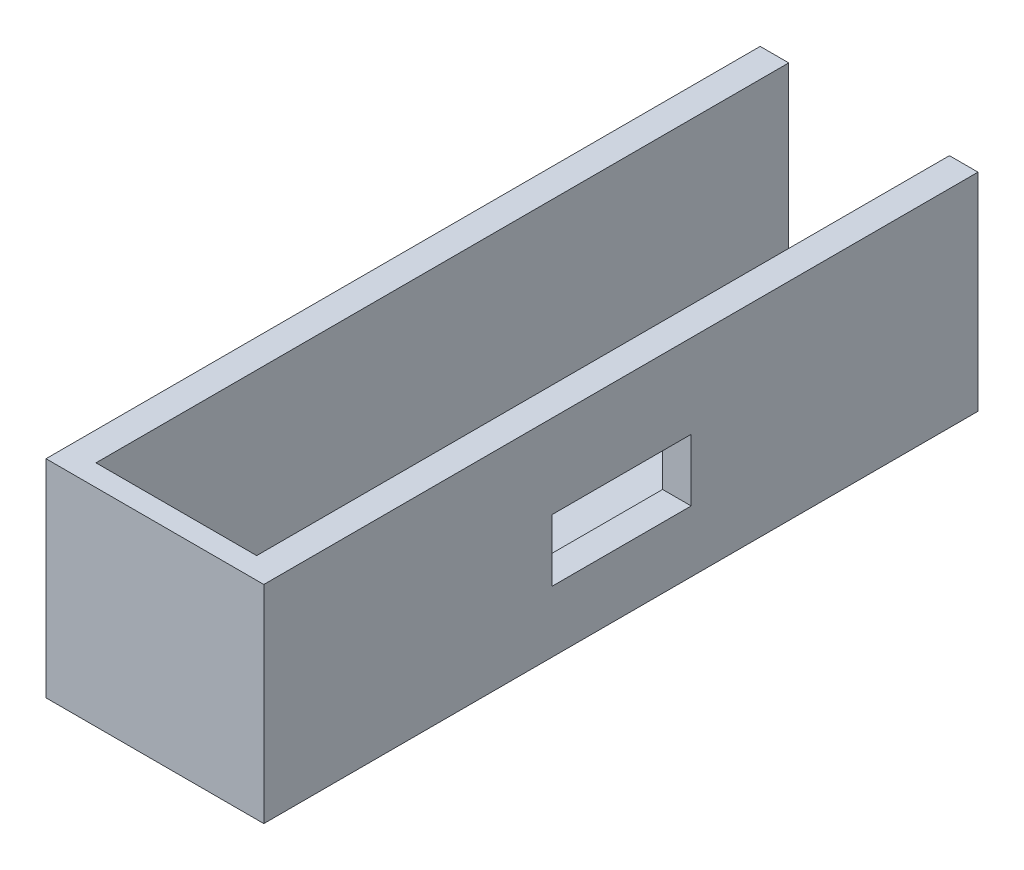
from build123d import *

# Parameters (mm, degrees)
BOSS_EXTRUDE1_DEPTH = 50
SKETCH2_W           = 30.5
SKETCH2_H           = 29
BOSS_EXTRUDE2_DEPTH = 3
SKETCH3_W           = 19.5
SKETCH3_H           = 8.69
CUT_EXTRUDE1_DEPTH  = 30


with BuildPart() as part:
    # Sketch1 → Boss-Extrude1 (new body, symmetric)
    with BuildSketch(Plane.XY):
        Polygon((-9.848648649, 0), (-9.848648649, -25), (12.651351351, -25), (12.651351351, 0), (16.651351351, 0), (16.651351351, -29), (-13.848648649, -29), (-13.848648649, 0), align=None)
    extrude(amount=BOSS_EXTRUDE1_DEPTH, both=True)

    # Sketch2 → Boss-Extrude2 (add)
    with BuildSketch(Plane.XY.offset(50)):
        with Locations((1.401351351, -14.5)):
            Rectangle(SKETCH2_W, SKETCH2_H)
    extrude(amount=-BOSS_EXTRUDE2_DEPTH)

    # Sketch3 → Cut-Extrude1 (cut)
    with BuildSketch(Plane(origin=(0, 0, 0), x_dir=(0, 0, -1), z_dir=(1, 0, 0))):
        with Locations((0.088778278, -16.052995557)):
            Rectangle(SKETCH3_W, SKETCH3_H)
    extrude(amount=CUT_EXTRUDE1_DEPTH, mode=Mode.SUBTRACT)


solid = part.part
